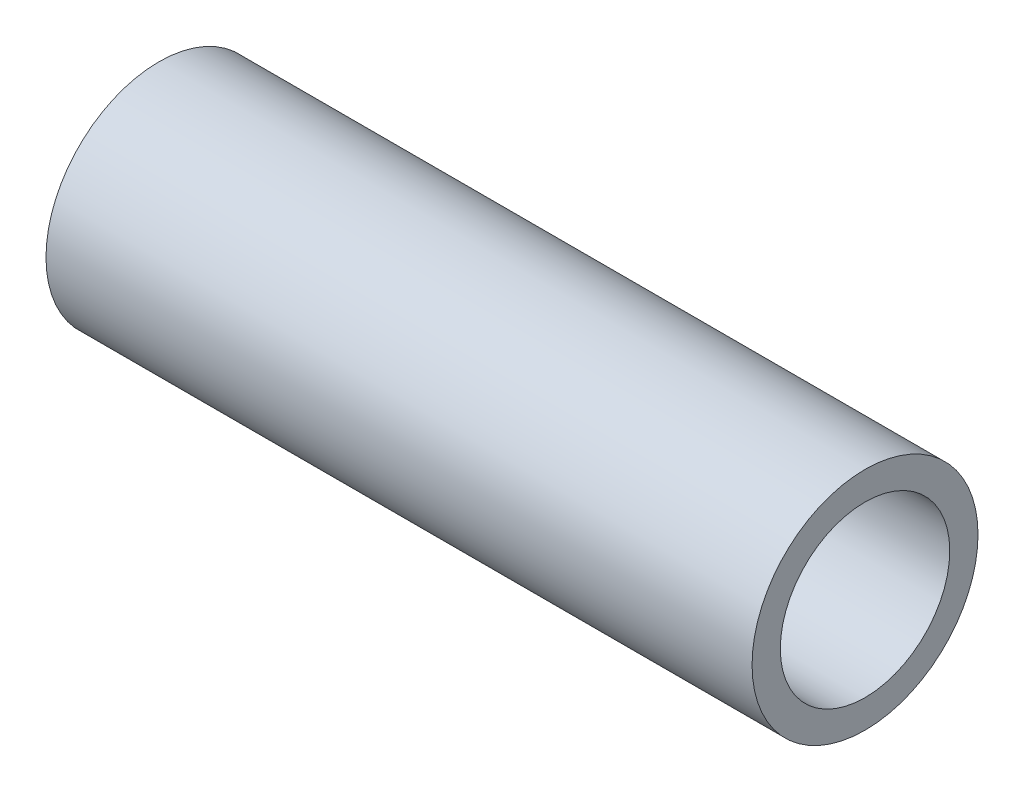
from build123d import *

# Parameters (mm, degrees)
SKETCH1_R           = 2
SKETCH1_R_2         = 1.5
BOSS_EXTRUDE1_DEPTH = 12.5


with BuildPart() as part:
    # Sketch1 → Boss-Extrude1 (new body)
    with BuildSketch(Plane(origin=(0, 0, 0), x_dir=(0, 0, -1), z_dir=(1, 0, 0))):
        Circle(SKETCH1_R)
        Circle(SKETCH1_R_2, mode=Mode.SUBTRACT)
    extrude(amount=BOSS_EXTRUDE1_DEPTH)


solid = part.part
